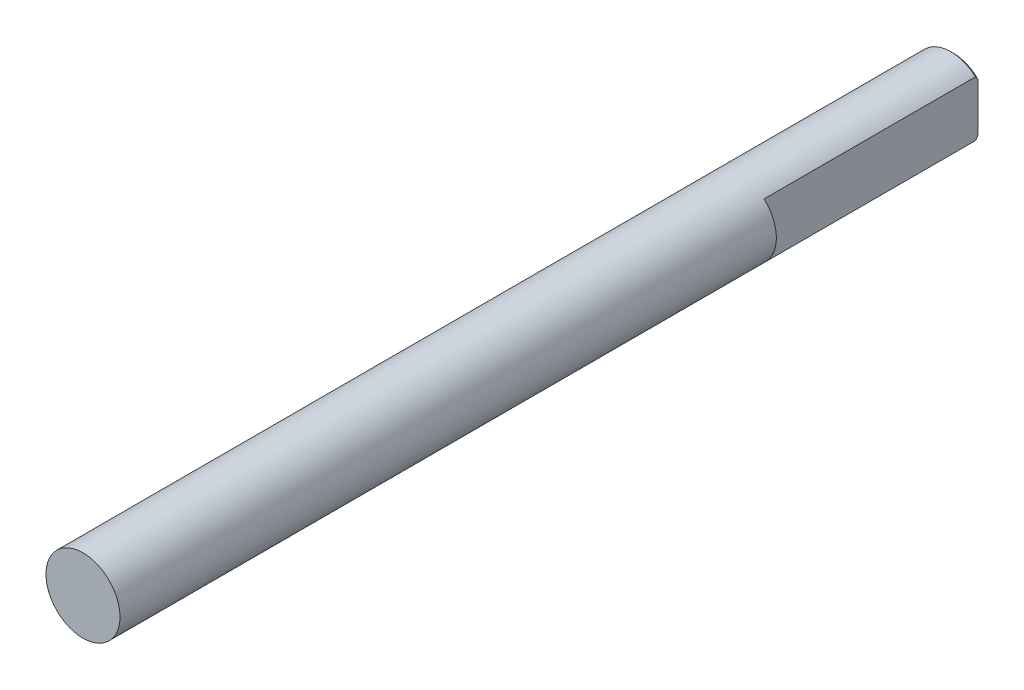
from build123d import *

# Parameters (mm, degrees)
SKETCH_1_R           = 1.5
EXTRUDE_1_DEPTH      = 26.6
SKETCH_2_R           = 1.5
EXTRUDE_2_DEPTH      = 8.67
CHAMFER_1_SIZE       = 0.1
SKETCH_3_OUTSIDE_W   = 12.104
SKETCH_3_OUTSIDE_H   = 12.104
SKETCH_3_OUTSIDE_W_2 = 2.5
SKETCH_3_OUTSIDE_H_2 = 3
CUT_EXTRUDE_1_DEPTH  = 8.67


with BuildPart() as part:
    # Эскиз1 → Бобышка-Вытянуть1 (new body)
    with BuildSketch(Plane.XY):
        Circle(SKETCH_1_R)
    extrude(amount=EXTRUDE_1_DEPTH)

    # Эскиз2 → Бобышка-Вытянуть2 (add)
    with BuildSketch(Plane(origin=(0, 0, 0), x_dir=(-1, 0, 0), z_dir=(0, 0, -1))):
        Circle(SKETCH_2_R)
    extrude(amount=EXTRUDE_2_DEPTH)

    # Фаска1
    chamfer_1_edges = [part.edges().sort_by_distance(p)[0] for p in [
        (1.5, 0, -8.67),
    ]]
    chamfer(chamfer_1_edges, length=CHAMFER_1_SIZE)

    # Эскиз3 outside → Вырез-Вытянуть1 (cut)
    with BuildSketch(Plane(origin=(0, 0, -8.67), x_dir=(-1, 0, 0), z_dir=(0, 0, -1))):
        Rectangle(SKETCH_3_OUTSIDE_W, SKETCH_3_OUTSIDE_H)
        with Locations((0.25, 0)):
            Rectangle(SKETCH_3_OUTSIDE_W_2, SKETCH_3_OUTSIDE_H_2, mode=Mode.SUBTRACT)
    extrude(amount=-CUT_EXTRUDE_1_DEPTH, mode=Mode.SUBTRACT)


solid = part.part
